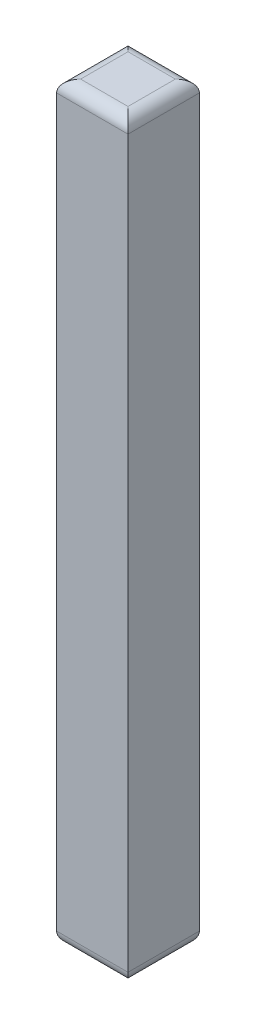
from build123d import *

# Parameters (mm, degrees)
SKETCH1_W           = 3.0226
SKETCH1_H           = 3.0226
BOSS_EXTRUDE1_DEPTH = 31.75
FILLET1_R           = 0.508


with BuildPart() as part:
    # Sketch1 → Boss-Extrude1 (new body)
    with BuildSketch(Plane(origin=(0, 0, 0), x_dir=(1, 0, 0), z_dir=(0, 1, 0))):
        with Locations((1.5113, 1.5113)):
            Rectangle(SKETCH1_W, SKETCH1_H)
    extrude(amount=BOSS_EXTRUDE1_DEPTH)

    # Fillet1
    fillet1_edges = [part.edges().sort_by_distance(p)[0] for p in [
        (3.0226, 31.75, -1.5113),
        (1.5113, 31.75, -3.0226),
        (0, 31.75, -1.5113),
        (1.5113, 0, -3.0226),
        (3.0226, 0, -1.5113),
        (1.5113, 0, 0),
        (0, 0, -1.5113),
        (1.5113, 31.75, 0),
    ]]
    fillet(fillet1_edges, radius=FILLET1_R)


solid = part.part
